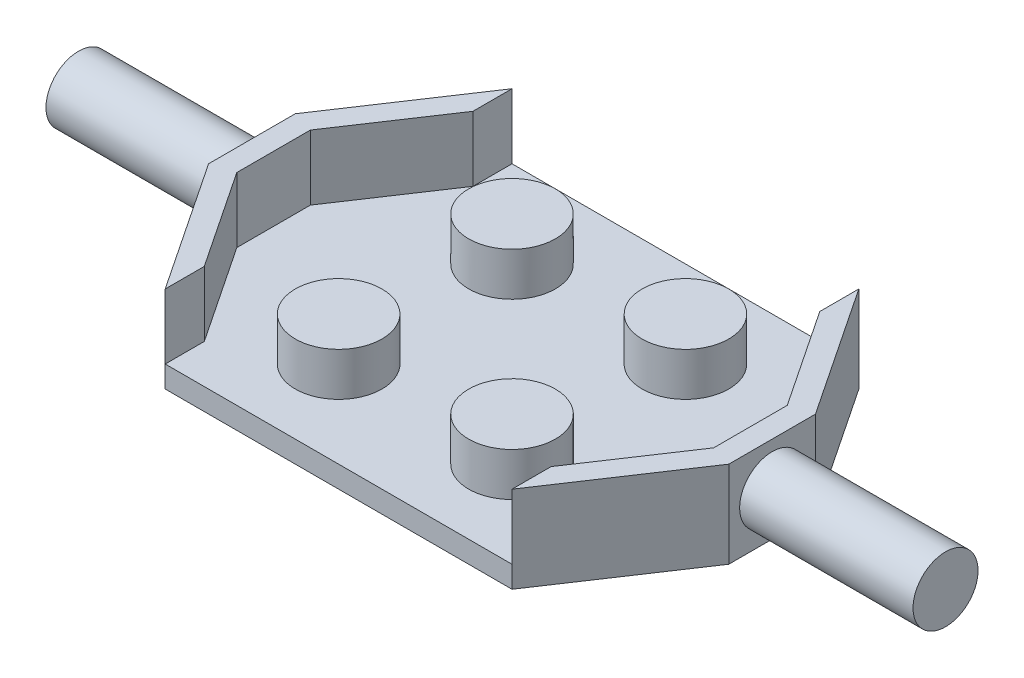
from build123d import *

# Parameters (mm, degrees)
BOSS_EXTRUDE1_DEPTH = 1
SKETCH2_R           = 2
BOSS_EXTRUDE2_DEPTH = 2
BOSS_EXTRUDE3_DEPTH = 3
SKETCH5_R           = 1.5
BOSS_EXTRUDE4_DEPTH = 8


with BuildPart() as part:
    # Sketch1 → Boss-Extrude1 (new body)
    with BuildSketch(Plane(origin=(0, 0, 0), x_dir=(1, 0, 0), z_dir=(0, 1, 0))):
        Polygon((0, -8), (0, 8), (-8, 8), (-12, 2), (-12, -2), (-8, -8), align=None)
    boss_extrude1 = extrude(amount=BOSS_EXTRUDE1_DEPTH)

    # Sketch2 → Boss-Extrude2 (add)
    with BuildSketch(Plane(origin=(0, 1, 0), x_dir=(1, 0, 0), z_dir=(0, 1, 0))):
        with Locations((-4, 4)):
            Circle(SKETCH2_R)
        with Locations((-4, -4)):
            Circle(SKETCH2_R)
    boss_extrude2 = extrude(amount=BOSS_EXTRUDE2_DEPTH)

    # Sketch3 → Boss-Extrude3 (add)
    with BuildSketch(Plane(origin=(0, 1, 0), x_dir=(1, 0, 0), z_dir=(0, 1, 0))):
        Polygon((-8, 6.197224362), (-11, 1.697224362), (-11, -1.697224362), (-8, -6.197224362), (-8, -8), (-12, -2), (-12, 2), (-8, 8), align=None)
    boss_extrude3 = extrude(amount=BOSS_EXTRUDE3_DEPTH)

    # Sketch5 → Boss-Extrude4 (add)
    with BuildSketch(Plane.ZY.offset(12)):
        with Locations((0, 2)):
            Circle(SKETCH5_R)
    boss_extrude4 = extrude(amount=BOSS_EXTRUDE4_DEPTH)

    # Mirror1: Boss-Extrude1, Boss-Extrude2, Boss-Extrude3, Boss-Extrude4 across plane
    add(boss_extrude1.mirror(Plane(origin=(0, 1, 8), x_dir=(0, 0, 1), z_dir=(-1, 0, 0))))
    add(boss_extrude2.mirror(Plane(origin=(0, 1, 8), x_dir=(0, 0, 1), z_dir=(-1, 0, 0))))
    add(boss_extrude3.mirror(Plane(origin=(0, 1, 8), x_dir=(0, 0, 1), z_dir=(-1, 0, 0))))
    add(boss_extrude4.mirror(Plane(origin=(0, 1, 8), x_dir=(0, 0, 1), z_dir=(-1, 0, 0))))


solid = part.part
